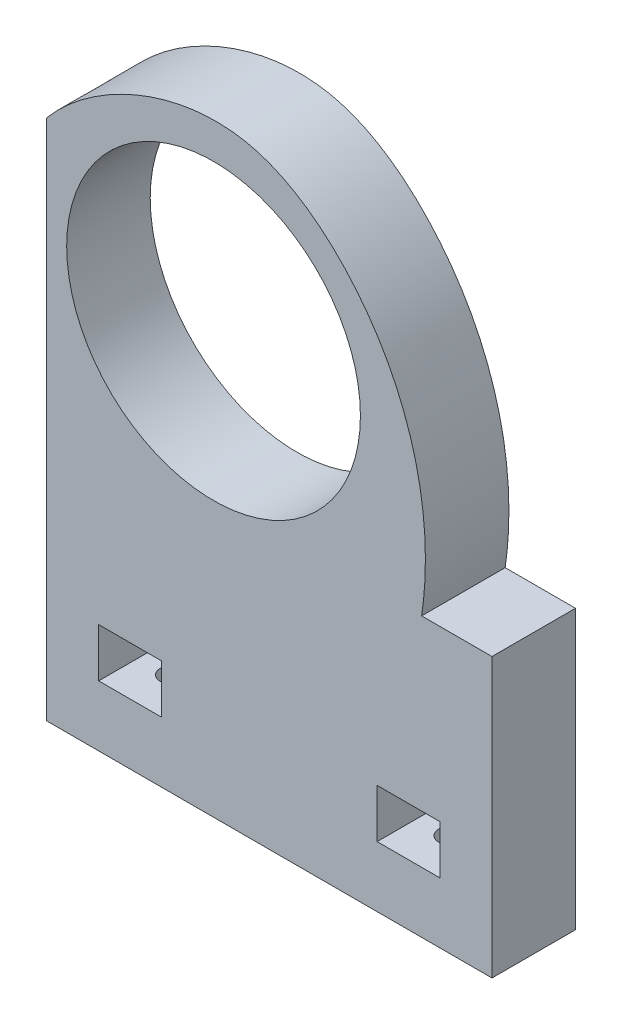
from build123d import *

# Parameters (mm, degrees)
SKETCH1_W           = 64
SKETCH1_H           = 40
BOSS_EXTRUDE1_DEPTH = 12
CUT_EXTRUDE1_DEPTH  = 13.0000001
SKETCH3_R           = 1.65
CUT_EXTRUDE4_DEPTH  = 10
SKETCH5_W           = 9
SKETCH5_H           = 7
CUT_EXTRUDE5_DEPTH  = 13.0000001


with BuildPart() as part:
    # Sketch1 → Boss-Extrude1 (new body)
    with BuildSketch(Plane.XY):
        with BuildLine():
            Line((-32, 55), (-32, 20))
            Line((-32, 20), (21.894736842, 20))
            add(Edge.make_bspline(
                [(-32, 55), (-25.467258538, 62.875582676), (-5.817351499, 72.029269909), (19.334385291, 52.075193803), (23.775907594, 32.709936379), (21.894736842, 20)],
                knots=[0, 0, 0, 0, 0.37053834, 0.573066511, 1, 1, 1, 1], degree=3))
        make_face()
        Rectangle(SKETCH1_W, SKETCH1_H)
    extrude(amount=BOSS_EXTRUDE1_DEPTH)

    # Sketch2 → Cut-Extrude1 (cut, through all)
    with BuildSketch(Plane.XY.offset(12)):
        with BuildLine():
            Line((4.2, 23.284599918), (4.2, 52.5))
            Line((4.2, 52.5), (-20.2, 52.5))
            Line((-20.2, 52.5), (-20.2, 23.284599918))
            ThreePointArc((-20.2, 23.284599918), (-8, 19.4), (4.2, 23.284599918))
        make_face()
        with BuildLine():
            Line((-20.2, 52.5), (4.2, 52.5))
            Line((4.2, 52.5), (4.2, 23.284599918))
            ThreePointArc((4.2, 23.284599918), (10.743398838, 30.81005676), (13.1, 40.5))
            ThreePointArc((13.1, 40.5), (-17.68994324, 59.243398838), (-20.2, 23.284599918))
            Line((-20.2, 23.284599918), (-20.2, 52.5))
        make_face()
    extrude(amount=-CUT_EXTRUDE1_DEPTH, mode=Mode.SUBTRACT)

    # Sketch3 → Cut-Extrude4 (cut)
    with BuildSketch(Plane.XZ.offset(20)):
        with Locations((-20, 6)):
            Circle(SKETCH3_R)
        with Locations((20, 6)):
            Circle(SKETCH3_R)
    extrude(amount=-CUT_EXTRUDE4_DEPTH, mode=Mode.SUBTRACT)

    # Sketch5 → Cut-Extrude5 (cut, through all)
    with BuildSketch(Plane.XY.offset(12)):
        with Locations((-20, -7.782850087)):
            Rectangle(SKETCH5_W, SKETCH5_H)
        with Locations((20, -7.782850087)):
            Rectangle(SKETCH5_W, SKETCH5_H)
    extrude(amount=-CUT_EXTRUDE5_DEPTH, mode=Mode.SUBTRACT)


solid = part.part
